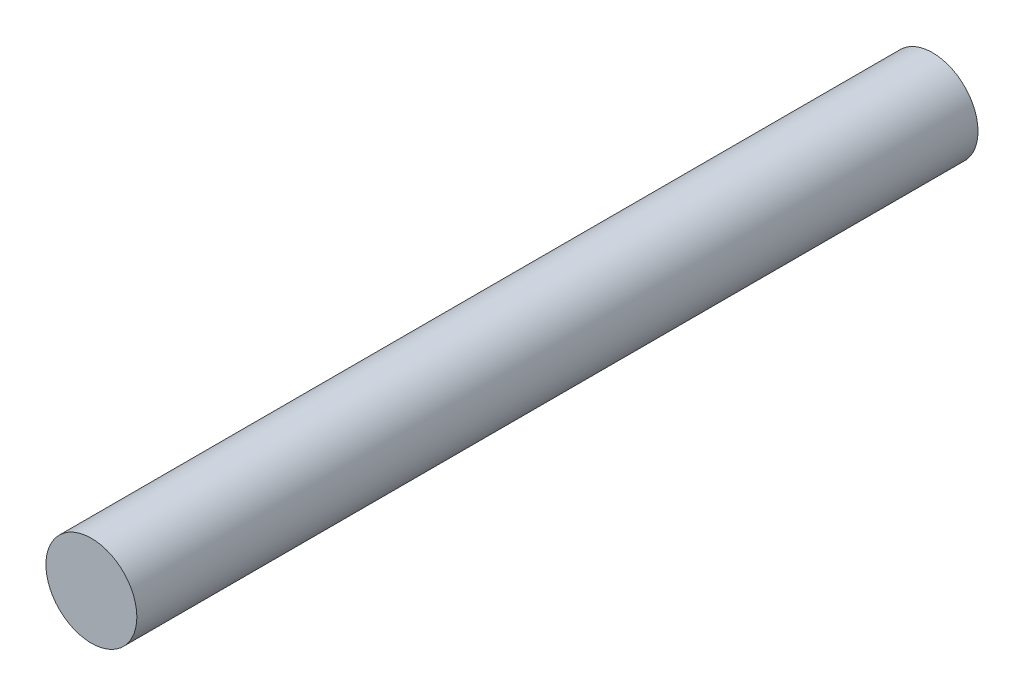
from build123d import *

# Parameters (mm, degrees)
SKETCH1_R           = 25.4
BOSS_EXTRUDE1_DEPTH = 234.95


with BuildPart() as part:
    # Sketch1 → Boss-Extrude1 (new body, symmetric)
    with BuildSketch(Plane.XY):
        Circle(SKETCH1_R)
    extrude(amount=BOSS_EXTRUDE1_DEPTH, both=True)


solid = part.part
